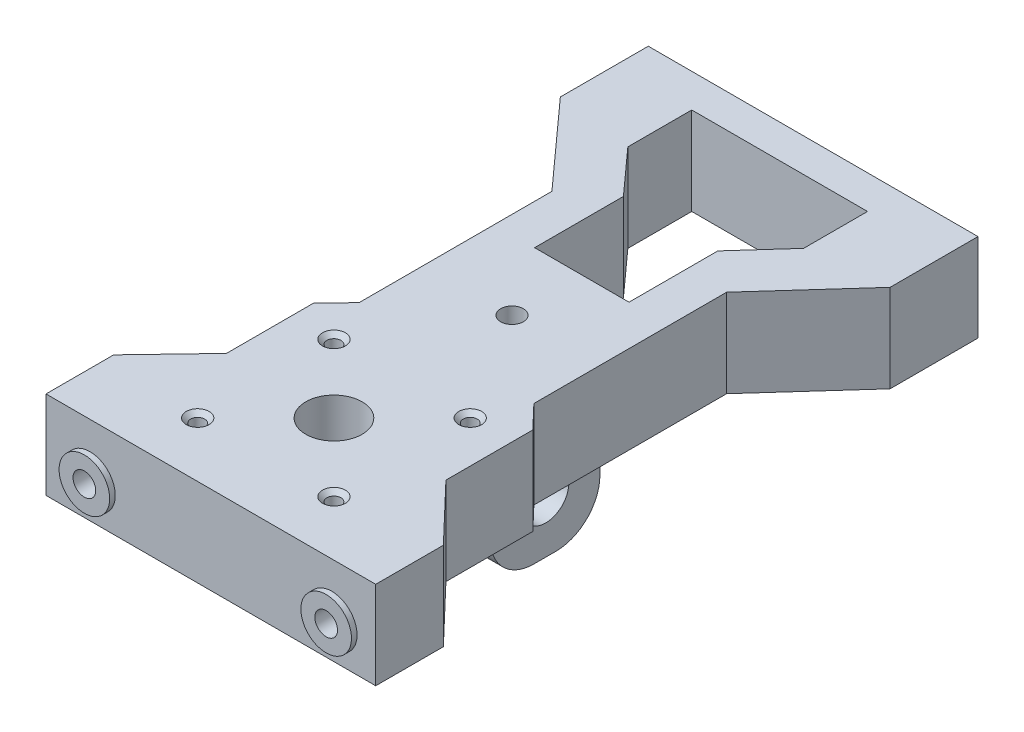
from build123d import *

# Parameters (mm, degrees)
SKETCH1_W                 = 68.5
SKETCH1_H                 = 20
BOSS_EXTRUDE1_DEPTH       = 75
SKETCH5_W                 = 15
SKETCH5_H                 = 25
BOSS_EXTRUDE2_DEPTH       = 24
SKETCH6_R                 = 5.25
CUT_EXTRUDE4_DEPTH        = 147.184814533
SKETCH2_W                 = 44
SKETCH2_H                 = 44
CUT_EXTRUDE1_DEPTH        = 7
SKETCH3_R                 = 6.4135
SKETCH3_R_2               = 1.6
CUT_EXTRUDE2_DEPTH        = 160.232534364
SKETCH4_R                 = 12.5
CUT_EXTRUDE3_DEPTH        = 3
CHAMFER1_SIZE             = 1
FILLET1_R                 = 10
FILLET2_R                 = 5
SKETCH16_R                = 2.5796875
CUT_EXTRUDE6_DEPTH        = 20
SKETCH7_R                 = 2.5796875
CUT_EXTRUDE7_DEPTH        = 12.7
BOSS_EXTRUDE3_START       = 1.27
SKETCH7_3_R               = 5.7546875
SKETCH7_3_R_2             = 2.5796875
BOSS_EXTRUDE3_DEPTH       = 1.27
MIRROR3_COPY_1_SKETCH_R   = 2.5796875
MIRROR3_COPY_1_DEPTH      = 12.7
MIRROR3_START             = 1.27
MIRROR3_COPY_2_SKETCH_R   = 5.7546875
MIRROR3_COPY_2_SKETCH_R_2 = 2.5796875
MIRROR3_COPY_2_DEPTH      = 1.27
CUT_EXTRUDE8_DEPTH        = 164.338889735


with BuildPart() as part:
    # Sketch1 → Boss-Extrude1 (new body)
    with BuildSketch(Plane(origin=(0, 0, 0), x_dir=(0, 0, -1), z_dir=(1, 0, 0))):
        with Locations((-34.25, 10)):
            Rectangle(SKETCH1_W, SKETCH1_H)
    boss_extrude1 = extrude(amount=BOSS_EXTRUDE1_DEPTH)

    # Mirror1: Boss-Extrude1 across plane
    add(boss_extrude1.mirror(Plane(origin=(75, 0, 68.5), x_dir=(1, 0, 0), z_dir=(0, 0, -1))))

    # Sketch5 → Boss-Extrude2 (add)
    with BuildSketch(Plane.XZ):
        with Locations((37.5, 68.5)):
            Rectangle(SKETCH5_W, SKETCH5_H)
    extrude(amount=BOSS_EXTRUDE2_DEPTH)

    # Sketch6 → Cut-Extrude4 (cut, through all)
    with BuildSketch(Plane.ZY.offset(-30)):
        with Locations((68.315835428, -12)):
            Circle(SKETCH6_R)
    extrude(amount=-CUT_EXTRUDE4_DEPTH, mode=Mode.SUBTRACT)

    # Sketch2 → Cut-Extrude1 (cut)
    with BuildSketch(Plane.XZ):
        with Locations((37.5, 109)):
            Rectangle(SKETCH2_W, SKETCH2_H)
    extrude(amount=-CUT_EXTRUDE1_DEPTH, mode=Mode.SUBTRACT)

    # Sketch3 → Cut-Extrude2 (cut, through all)
    with BuildSketch(Plane.XZ.offset(-7)):
        with Locations((37.5, 109)):
            Circle(SKETCH3_R)
        with Locations((22, 93.5)):
            Circle(SKETCH3_R_2)
        with Locations((22, 124.5)):
            Circle(SKETCH3_R_2)
        with Locations((53, 124.5)):
            Circle(SKETCH3_R_2)
        with Locations((53, 93.5)):
            Circle(SKETCH3_R_2)
    extrude(amount=-CUT_EXTRUDE2_DEPTH, mode=Mode.SUBTRACT)

    # Sketch4 → Cut-Extrude3 (cut)
    with BuildSketch(Plane.XZ.offset(-7)):
        with Locations((37.5, 109)):
            Circle(SKETCH4_R)
    extrude(amount=-CUT_EXTRUDE3_DEPTH, mode=Mode.SUBTRACT)

    # Chamfer1
    chamfer1_edges = [part.edges().sort_by_distance(p)[0] for p in [
        (20.4, 20, 124.5),
        (51.4, 20, 124.5),
        (51.4, 20, 93.5),
        (20.4, 20, 93.5),
    ]]
    chamfer(chamfer1_edges, length=CHAMFER1_SIZE)

    # Fillet1
    fillet1_edges = [part.edges().sort_by_distance(p)[0] for p in [
        (37.5, -24, 56),
        (37.5, -24, 81),
    ]]
    fillet(fillet1_edges, radius=FILLET1_R)

    # Fillet2
    fillet2_edges = [part.edges().sort_by_distance(p)[0] for p in [
        (30, 0, 68.5),
    ]]
    fillet(fillet2_edges, radius=FILLET2_R)

    # Sketch16 → Cut-Extrude6 (cut)
    with BuildSketch(Plane(origin=(0, 20, 0), x_dir=(1, 0, 0), z_dir=(0, 1, 0))):
        with Locations((37.5, -68.5)):
            Circle(SKETCH16_R)
    extrude(amount=-CUT_EXTRUDE6_DEPTH, mode=Mode.SUBTRACT)

    # Sketch7 → Cut-Extrude7 (cut)
    with BuildSketch(Plane(origin=(0, 0, 0), x_dir=(-1, 0, 0), z_dir=(0, 0, -1))):
        with Locations((-10, 7.874)):
            Circle(SKETCH7_R)
    cut_extrude7 = extrude(amount=-CUT_EXTRUDE7_DEPTH, mode=Mode.SUBTRACT)

    # Sketch7_3 → Boss-Extrude3 (add)
    with BuildSketch(Plane(origin=(0, 0, 0), x_dir=(-1, 0, 0), z_dir=(0, 0, -1)).offset(BOSS_EXTRUDE3_START)):
        with Locations((-10, 7.874)):
            Circle(SKETCH7_3_R)
        with Locations((-10, 7.874)):
            Circle(SKETCH7_3_R_2, mode=Mode.SUBTRACT)
    boss_extrude3 = extrude(amount=-BOSS_EXTRUDE3_DEPTH)

    # Mirror2: Cut-Extrude7, Boss-Extrude3 across plane
    add(cut_extrude7.mirror(Plane.ZY.offset(-37.5)), mode=Mode.SUBTRACT)
    add(boss_extrude3.mirror(Plane.ZY.offset(-37.5)))

    # Mirror3: Cut-Extrude7, Boss-Extrude3 across plane
    add(cut_extrude7.mirror(Plane.XY.offset(68.5)), mode=Mode.SUBTRACT)
    add(boss_extrude3.mirror(Plane.XY.offset(68.5)))

    # Mirror3 copy 1 sketch → Mirror3 copy 1 (cut)
    with BuildSketch(Plane(origin=(75, 0, 137), x_dir=(1, 0, 0), z_dir=(0, 0, 1))):
        with Locations((-10, 7.874)):
            Circle(MIRROR3_COPY_1_SKETCH_R)
    extrude(amount=-MIRROR3_COPY_1_DEPTH, mode=Mode.SUBTRACT)

    # Mirror3 copy 2 sketch → Mirror3 copy 2 (add)
    with BuildSketch(Plane(origin=(75, 0, 137), x_dir=(1, 0, 0), z_dir=(0, 0, 1)).offset(MIRROR3_START)):
        with Locations((-10, 7.874)):
            Circle(MIRROR3_COPY_2_SKETCH_R)
        with Locations((-10, 7.874)):
            Circle(MIRROR3_COPY_2_SKETCH_R_2, mode=Mode.SUBTRACT)
    extrude(amount=-MIRROR3_COPY_2_DEPTH)

    # Sketch18 → Cut-Extrude8 (cut, through all)
    with BuildSketch(Plane(origin=(0, 20, 0), x_dir=(1, 0, 0), z_dir=(0, 1, 0))):
        Polygon((62.458777686, -88.720593409), (57.373918935, -83.400245236), (57.373918935, -39.549393127), (75, -20), (75, -121.613031971), (62.458777686, -108.491001941), align=None)
        Polygon((48.237394794, -32.421103895), (48.237394794, -52.62), (37.493383725, -52.62), (37.493383725, -7.62), (57.493383725, -7.62), (57.493383725, -22.155125557), align=None)
    cut_extrude8 = extrude(amount=-CUT_EXTRUDE8_DEPTH, mode=Mode.SUBTRACT)

    # Mirror4: Cut-Extrude8 across plane
    add(cut_extrude8.mirror(Plane.ZY.offset(-37.5)), mode=Mode.SUBTRACT)


solid = part.part
